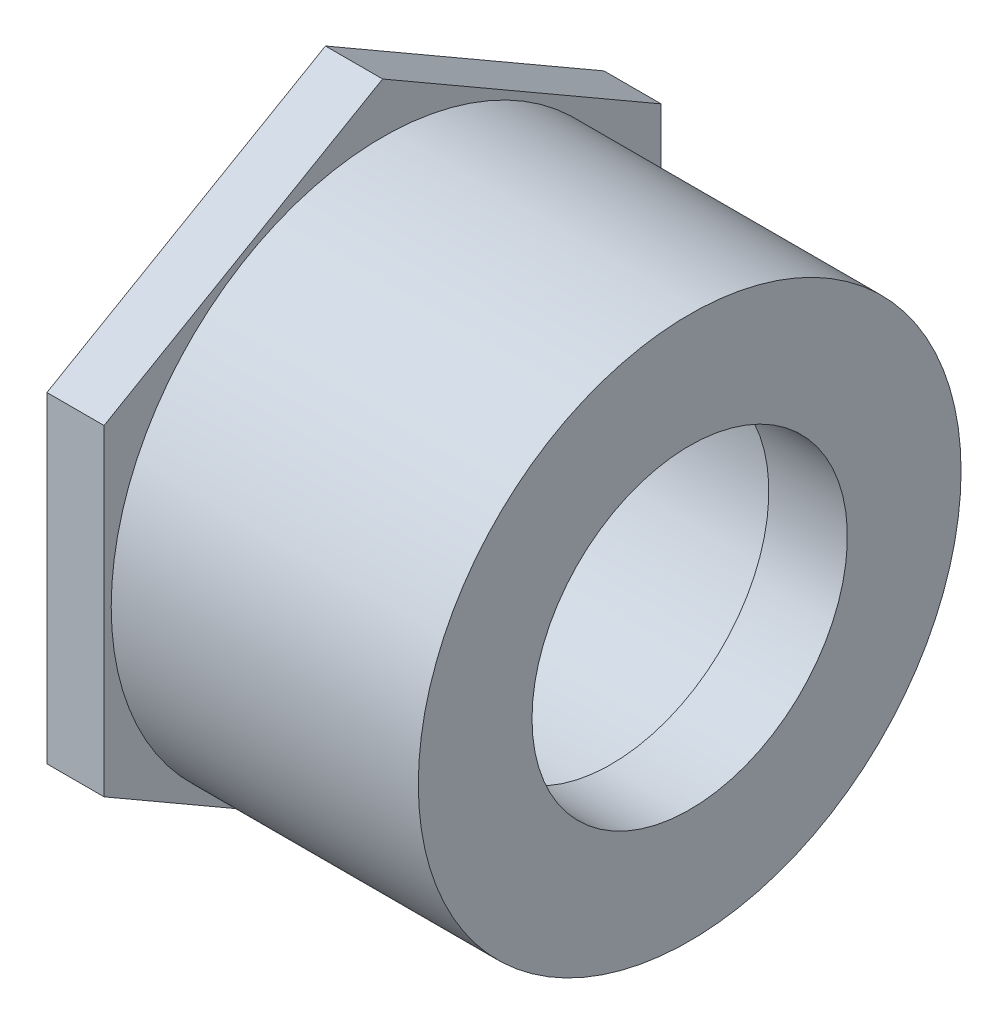
from build123d import *

# Parameters (mm, degrees)
SKETCH2_R           = 21.209
BOSS_EXTRUDE1_DEPTH = 6.35


with BuildPart() as part:
    # Sketch1 → Revolve1 (revolve)
    with BuildSketch(Plane.XY):
        Polygon((-40.48125, -30.1625), (0, -30.1625), (0, -17.526), (-8.73125, -17.526), (-8.73125, -21.0185), (-40.48125, -21.209), align=None)
    revolve(axis=Axis((-40.48125, 0, 0), (1, 0, 0)))

    # Sketch2 → Boss-Extrude1 (add)
    with BuildSketch(Plane.ZY.offset(40.48125)):
        Polygon((0, 35.745198541), (-30.95625, 17.872599271), (-30.95625, -17.872599271), (0, -35.745198541), (30.95625, -17.872599271), (30.95625, 17.872599271), align=None)
        Circle(SKETCH2_R, mode=Mode.SUBTRACT)
    extrude(amount=-BOSS_EXTRUDE1_DEPTH)


solid = part.part
